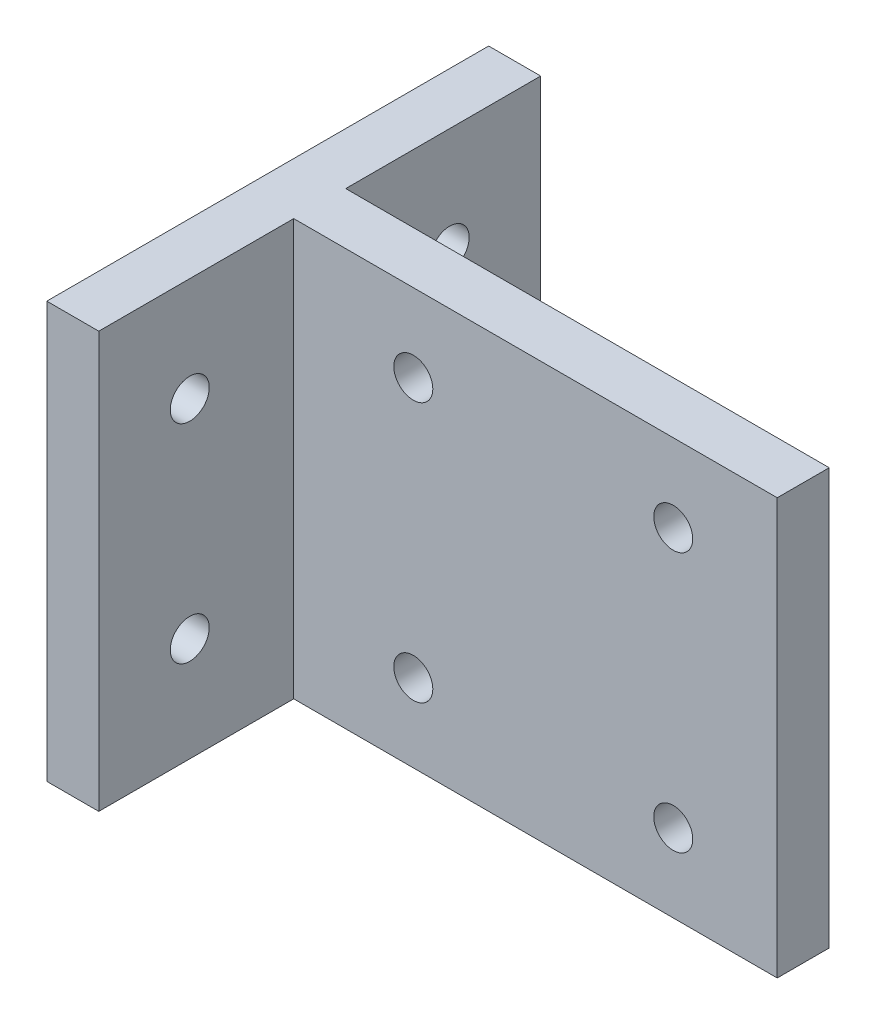
from build123d import *

# Parameters (mm, degrees)
SKETCH_1_W          = 36
SKETCH_1_H          = 32
SKETCH_1_R          = 1.5
EXTRUDE_1_DEPTH     = 4
EXTRUDE_2_DEPTH     = 32
SKETCH_8_R          = 1.5
CUT_EXTRUDE_1_DEPTH = 5


with BuildPart() as part:
    # Эскиз1 → Бобышка-Вытянуть1 (new body)
    with BuildSketch(Plane.XY):
        with Locations((18, 16)):
            Rectangle(SKETCH_1_W, SKETCH_1_H)
        with Locations((8, 26)):
            Circle(SKETCH_1_R, mode=Mode.SUBTRACT)
        with Locations((28, 26)):
            Circle(SKETCH_1_R, mode=Mode.SUBTRACT)
        with Locations((8, 6)):
            Circle(SKETCH_1_R, mode=Mode.SUBTRACT)
        with Locations((28, 6)):
            Circle(SKETCH_1_R, mode=Mode.SUBTRACT)
    extrude(amount=EXTRUDE_1_DEPTH)

    # Эскиз7 → Бобышка-Вытянуть2 (add)
    with BuildSketch(Plane(origin=(0, 32, 0), x_dir=(1, 0, 0), z_dir=(0, 1, 0))):
        Polygon((0, 0), (-1.2, 0), (-1.2, 15), (-5.2, 15), (-5.2, -19), (-1.2, -19), (-1.2, -4), (0, -4), align=None)
    extrude(amount=-EXTRUDE_2_DEPTH)

    # Эскиз8 → Вырез-Вытянуть1 (cut, through all)
    with BuildSketch(Plane(origin=(-1.2, 0, 0), x_dir=(0, 0, -1), z_dir=(1, 0, 0))):
        with Locations((8, 24)):
            Circle(SKETCH_8_R)
        with Locations((8, 8)):
            Circle(SKETCH_8_R)
        with Locations((-12, 8)):
            Circle(SKETCH_8_R)
        with Locations((-12, 24)):
            Circle(SKETCH_8_R)
    extrude(amount=-CUT_EXTRUDE_1_DEPTH, mode=Mode.SUBTRACT)


solid = part.part
